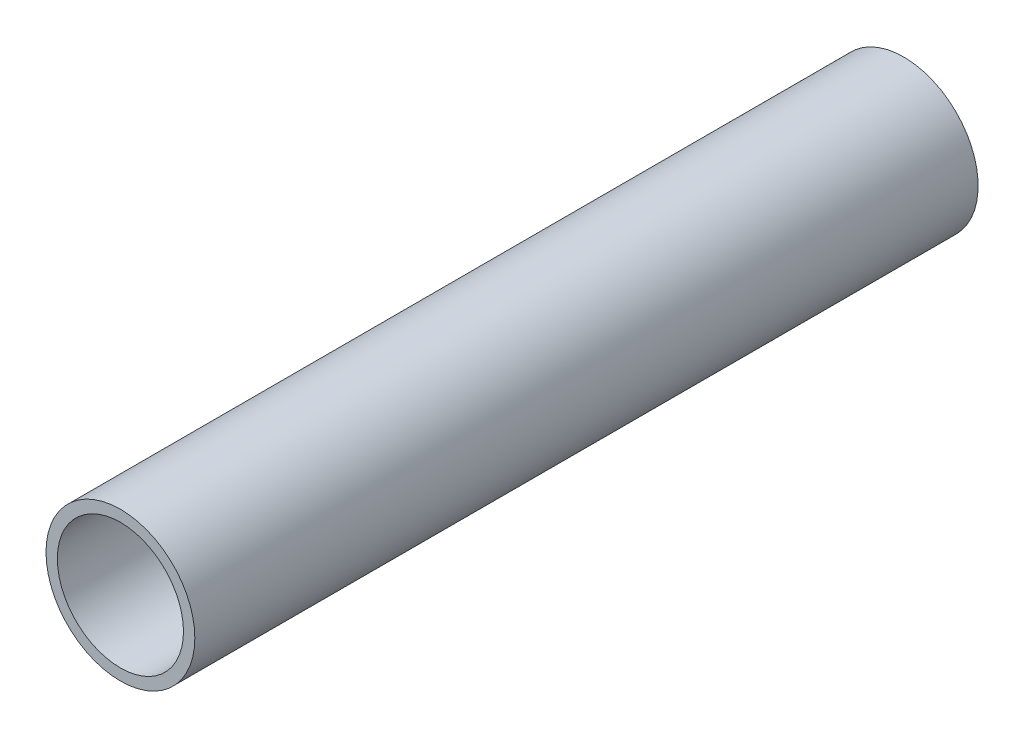
from build123d import *

# Parameters (mm, degrees)
SKETCH1_W          = 3.683
SKETCH1_H          = 1524
SKETCH2_R          = 33.655294881
CUT_EXTRUDE1_DEPTH = 1270


with BuildPart() as part:
    # Sketch1 → Revolve1 (revolve)
    with BuildSketch(Plane.XZ):
        with Locations((22.2885, 0)):
            Rectangle(SKETCH1_W, SKETCH1_H)
    revolve(axis=Axis((0, 0, 762), (0, 0, -1)))

    # Sketch2 → Cut-Extrude1 (cut)
    with BuildSketch(Plane.XY.offset(762)):
        Circle(SKETCH2_R)
    extrude(amount=-CUT_EXTRUDE1_DEPTH, mode=Mode.SUBTRACT)


solid = part.part
